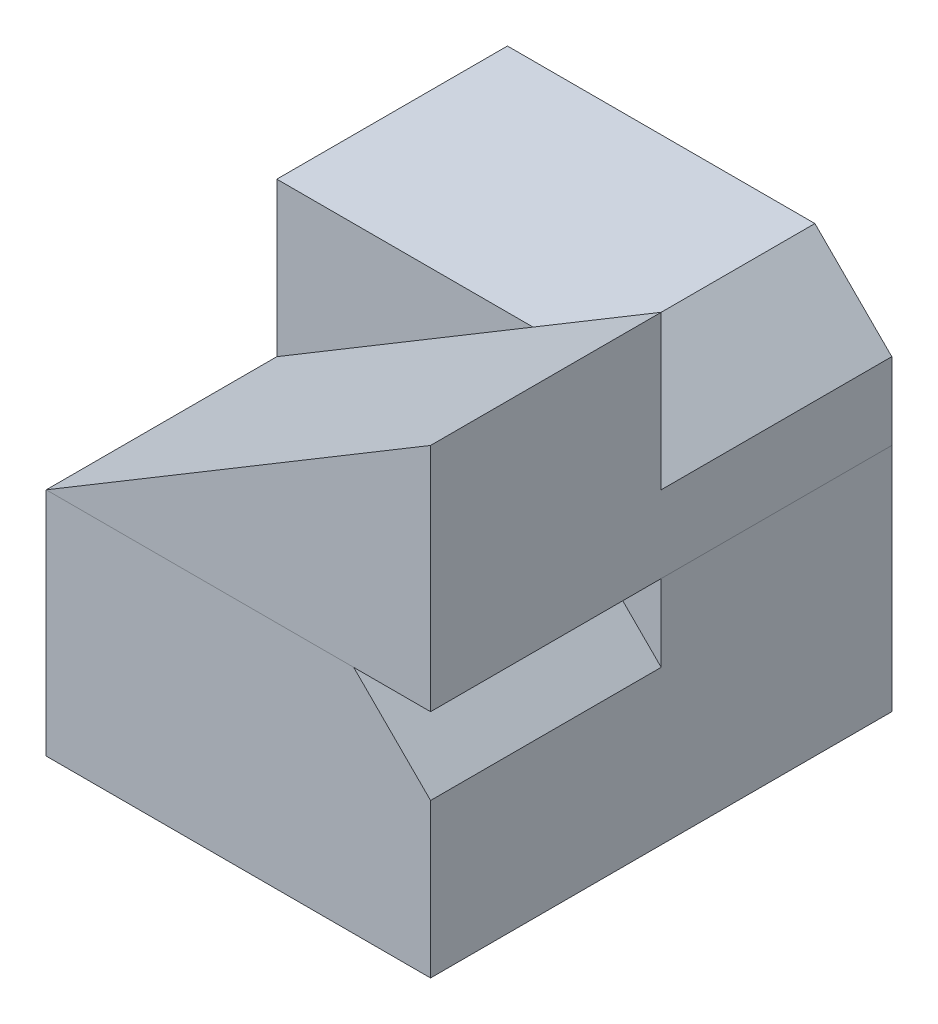
from build123d import *

# Parameters (mm, degrees)
BOSS_EXTRUDE1_DEPTH = 15
BOSS_EXTRUDE2_DEPTH = 15
BOSS_EXTRUDE4_DEPTH = 15
BOSS_EXTRUDE5_DEPTH = 15


with BuildPart() as part:
    # Sketch1 → Boss-Extrude1 (new body)
    with BuildSketch(Plane.XY):
        Polygon((-25, 0), (0, 0), (0, 15), align=None)
    extrude(amount=BOSS_EXTRUDE1_DEPTH)

    # Sketch2 → Boss-Extrude2 (add)
    with BuildSketch(Plane.XY.offset(15)):
        Polygon((-25, 0), (-25, 15), (-5, 15), (0, 10), (0, 0), align=None)
    extrude(amount=BOSS_EXTRUDE2_DEPTH)


with BuildPart() as body_2:
    # Sketch3 → Boss-Extrude4 (new body)
    with BuildSketch(Plane.XY.offset(15)):
        Polygon((-25, 15), (0, 15), (0, 30), align=None)
    extrude(amount=BOSS_EXTRUDE4_DEPTH)

    # Sketch5 → Boss-Extrude5 (add)
    with BuildSketch(Plane(origin=(0, 0, 15), x_dir=(-1, 0, 0), z_dir=(0, 0, -1))):
        Polygon((25, 15), (25, 25), (5, 25), (0, 20), (0, 15), align=None)
    extrude(amount=BOSS_EXTRUDE5_DEPTH)


solid = Compound([part.part, body_2.part])
